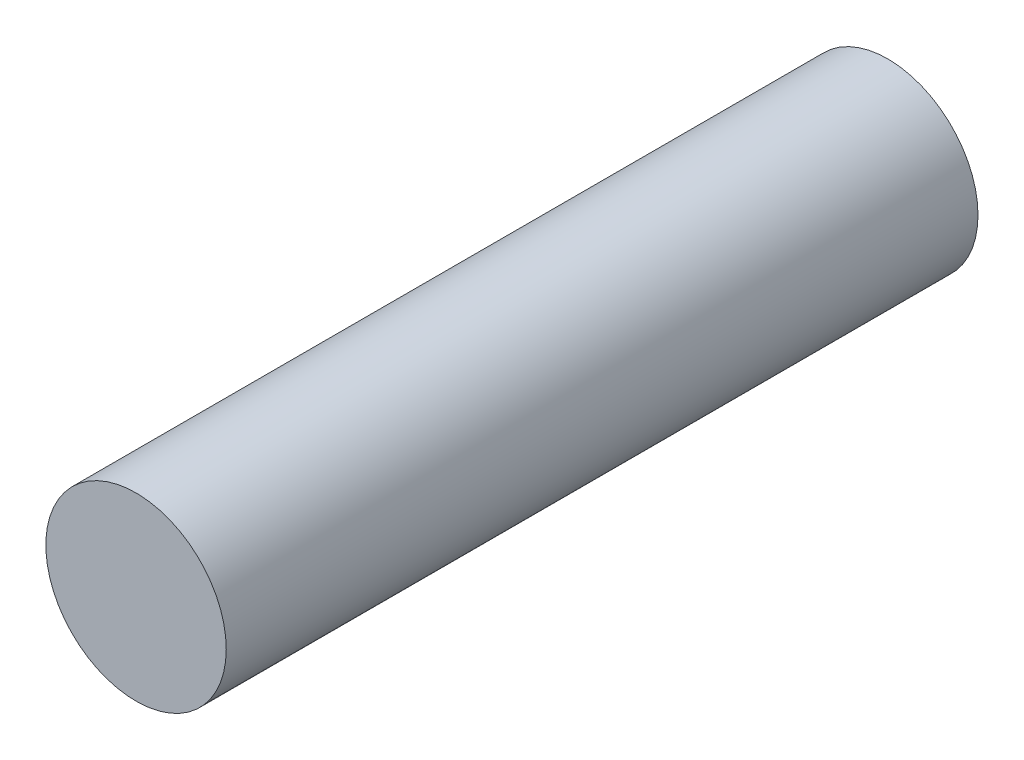
from build123d import *

# Parameters (mm, degrees)
SKETCH2_R           = 6
BOSS_EXTRUDE1_DEPTH = 50


with BuildPart() as part:
    # Sketch2 → Boss-Extrude1 (new body)
    with BuildSketch(Plane.XY):
        Circle(SKETCH2_R)
    extrude(amount=BOSS_EXTRUDE1_DEPTH)


solid = part.part
